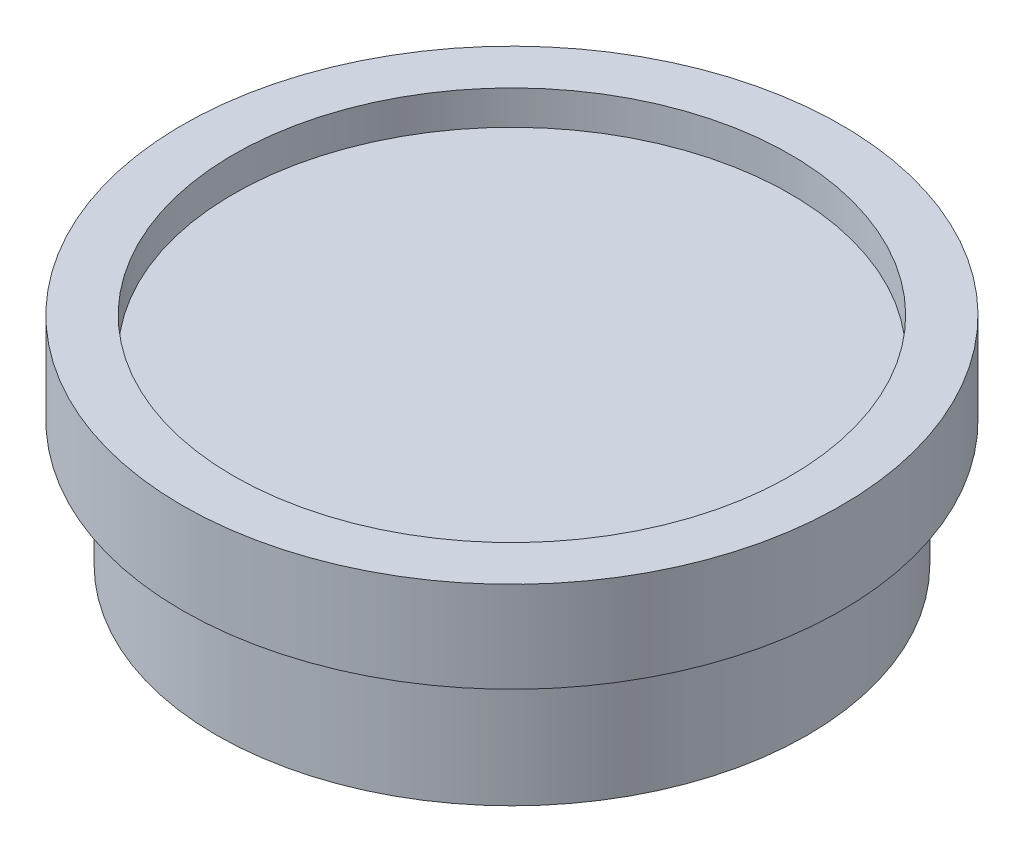
from build123d import *

# Parameters (mm, degrees)
SKETCH1_R           = 29
BOSS_EXTRUDE1_DEPTH = 8
SKETCH2_R           = 26
BOSS_EXTRUDE2_DEPTH = 11
SKETCH3_R           = 24.5
CUT_EXTRUDE1_DEPTH  = 3


with BuildPart() as part:
    # Sketch1 → Boss-Extrude1 (new body)
    with BuildSketch(Plane(origin=(0, 0, 0), x_dir=(1, 0, 0), z_dir=(0, 1, 0))):
        Circle(SKETCH1_R)
    extrude(amount=-BOSS_EXTRUDE1_DEPTH)

    # Sketch2 → Boss-Extrude2 (add)
    with BuildSketch(Plane.XZ.offset(8)):
        Circle(SKETCH2_R)
    extrude(amount=BOSS_EXTRUDE2_DEPTH)

    # Sketch3 → Cut-Extrude1 (cut)
    with BuildSketch(Plane(origin=(0, 0, 0), x_dir=(1, 0, 0), z_dir=(0, 1, 0))):
        Circle(SKETCH3_R)
    extrude(amount=-CUT_EXTRUDE1_DEPTH, mode=Mode.SUBTRACT)


solid = part.part
